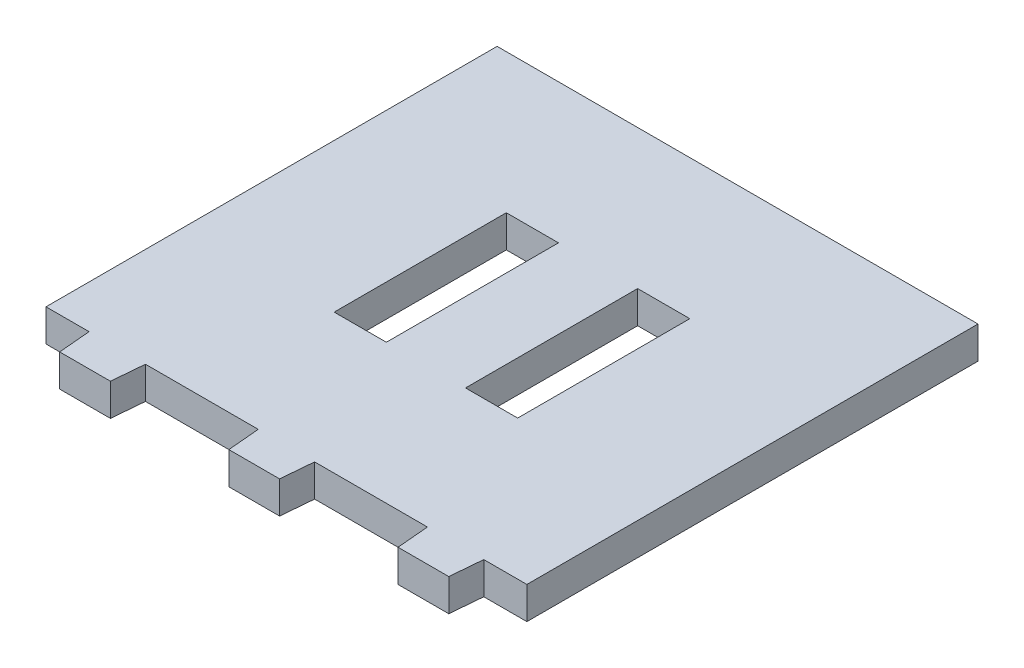
from build123d import *

# Parameters (mm, degrees)
SKETCH2_W           = 85.279590556
SKETCH2_H           = 80
SKETCH2_W_2         = 9.25294304
SKETCH2_H_2         = 30.528437524
BOSS_EXTRUDE1_DEPTH = 5.715


with BuildPart() as part:
    # Sketch2 → Boss-Extrude1 (new body)
    with BuildSketch(Plane(origin=(0, 0, 0), x_dir=(1, 0, 0), z_dir=(0, 1, 0))):
        Rectangle(SKETCH2_W, SKETCH2_H)
        with Locations((-11.645107557, 0)):
            Rectangle(SKETCH2_W_2, SKETCH2_H_2, mode=Mode.SUBTRACT)
        with Locations((11.645107557, 0)):
            Rectangle(SKETCH2_W_2, SKETCH2_H_2, mode=Mode.SUBTRACT)
        Polygon((-25, -40), (-35, -40), (-34.5, -45.715), (-25.5, -45.715), align=None)
        Polygon((5, -40), (-5, -40), (-4.5, -45.715), (4.5, -45.715), align=None)
        Polygon((34.5, -45.715), (35, -40), (25, -40), (25.5, -45.715), align=None)
    extrude(amount=BOSS_EXTRUDE1_DEPTH)


solid = part.part
